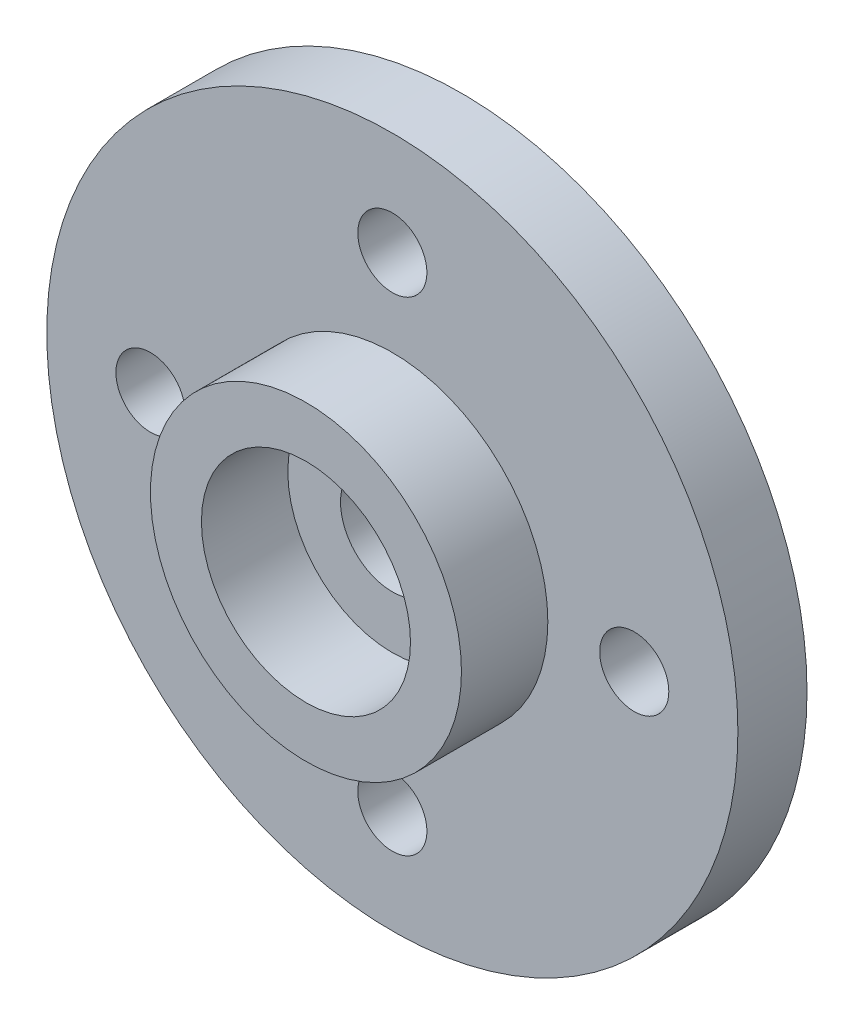
from build123d import *

# Parameters (mm, degrees)
SKETCH1_R           = 10
SKETCH1_R_2         = 1
SKETCH1_R_3         = 1.5
BOSS_EXTRUDE1_DEPTH = 2
SKETCH2_R           = 4.5
SKETCH2_R_2         = 3.025
BOSS_EXTRUDE2_DEPTH = 2.5


with BuildPart() as part:
    # Sketch1 → Boss-Extrude1 (new body)
    with BuildSketch(Plane.XY):
        Circle(SKETCH1_R)
        with Locations((7, 0)):
            Circle(SKETCH1_R_2, mode=Mode.SUBTRACT)
        with Locations((0, 7)):
            Circle(SKETCH1_R_2, mode=Mode.SUBTRACT)
        Circle(SKETCH1_R_3, mode=Mode.SUBTRACT)
        with Locations((0, -7)):
            Circle(SKETCH1_R_2, mode=Mode.SUBTRACT)
        with Locations((-7, 0)):
            Circle(SKETCH1_R_2, mode=Mode.SUBTRACT)
    extrude(amount=BOSS_EXTRUDE1_DEPTH)

    # Sketch2 → Boss-Extrude2 (add)
    with BuildSketch(Plane.XY.offset(2)):
        Circle(SKETCH2_R)
        Circle(SKETCH2_R_2, mode=Mode.SUBTRACT)
    extrude(amount=BOSS_EXTRUDE2_DEPTH)


solid = part.part
